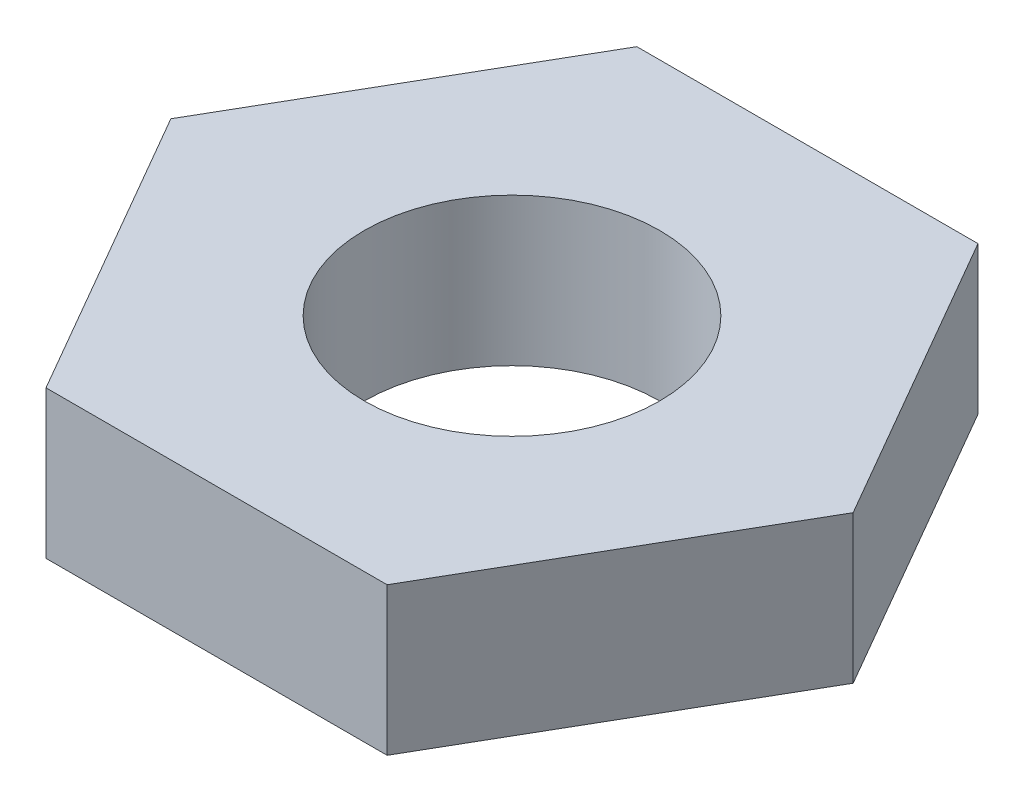
from build123d import *

# Parameters (mm, degrees)
SKETCH_1_R      = 2.5
EXTRUDE_1_DEPTH = 2.5


with BuildPart() as part:
    # Эскиз1 → Бобышка-Вытянуть1 (new body)
    with BuildSketch(Plane(origin=(0, 0, 0), x_dir=(1, 0, 0), z_dir=(0, 1, 0))):
        Polygon((-5.773502692, 0), (-2.886751346, -5), (2.886751346, -5), (5.773502692, 0), (2.886751346, 5), (-2.886751346, 5), align=None)
        Circle(SKETCH_1_R, mode=Mode.SUBTRACT)
    extrude(amount=EXTRUDE_1_DEPTH)


solid = part.part
